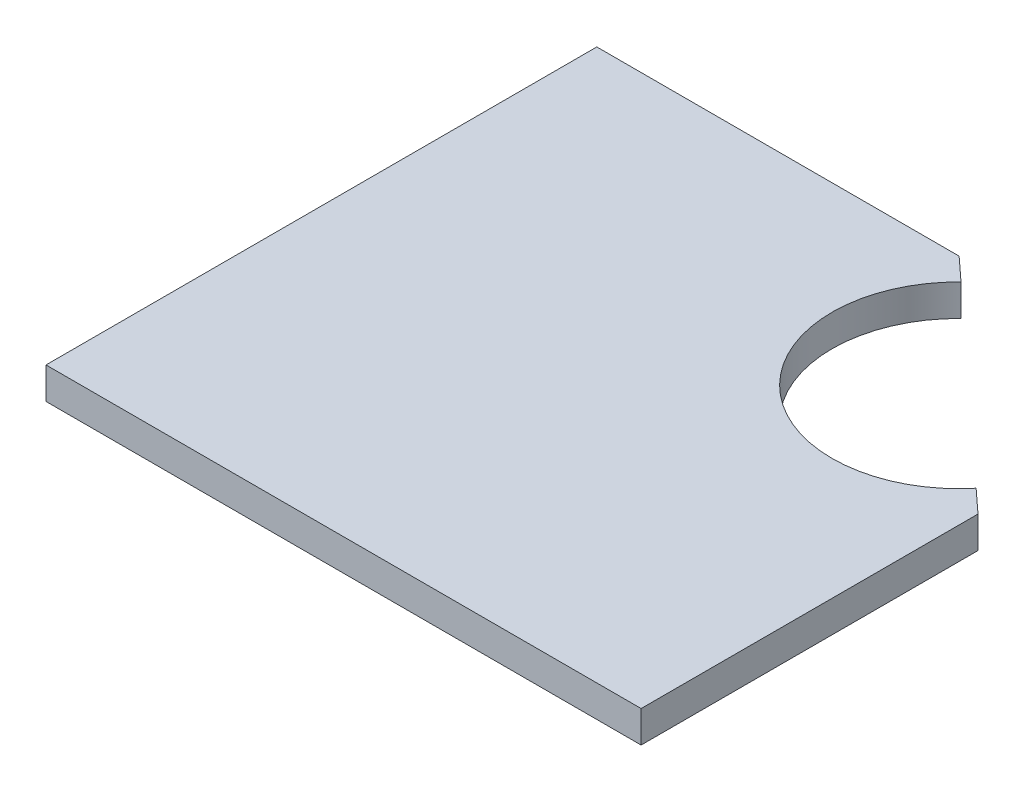
from build123d import *

# Parameters (mm, degrees)
BOSS_EXTRU_1_DEPTH = 5


with BuildPart() as part:
    # Esquisse1 → Boss.-Extru.1 (new body)
    with BuildSketch(Plane(origin=(0, 0, 0), x_dir=(1, 0, 0), z_dir=(0, 1, 0))):
        with BuildLine():
            Line((-47, 43.5), (10.228465539, 43.5))
            Line((10.228465539, 43.5), (13.910137535, 40.116910981))
            ThreePointArc((13.910137535, 40.116910981), (14.332580008, 11.063199665), (43.318328003, 13.093719798))
            Line((43.318328003, 13.093719798), (47, 9.710630779))
            Line((47, 9.710630779), (47, -43.5))
            Line((47, -43.5), (-47, -43.5))
            Line((-47, -43.5), (-47, 43.5))
        make_face()
    extrude(amount=BOSS_EXTRU_1_DEPTH)


solid = part.part
